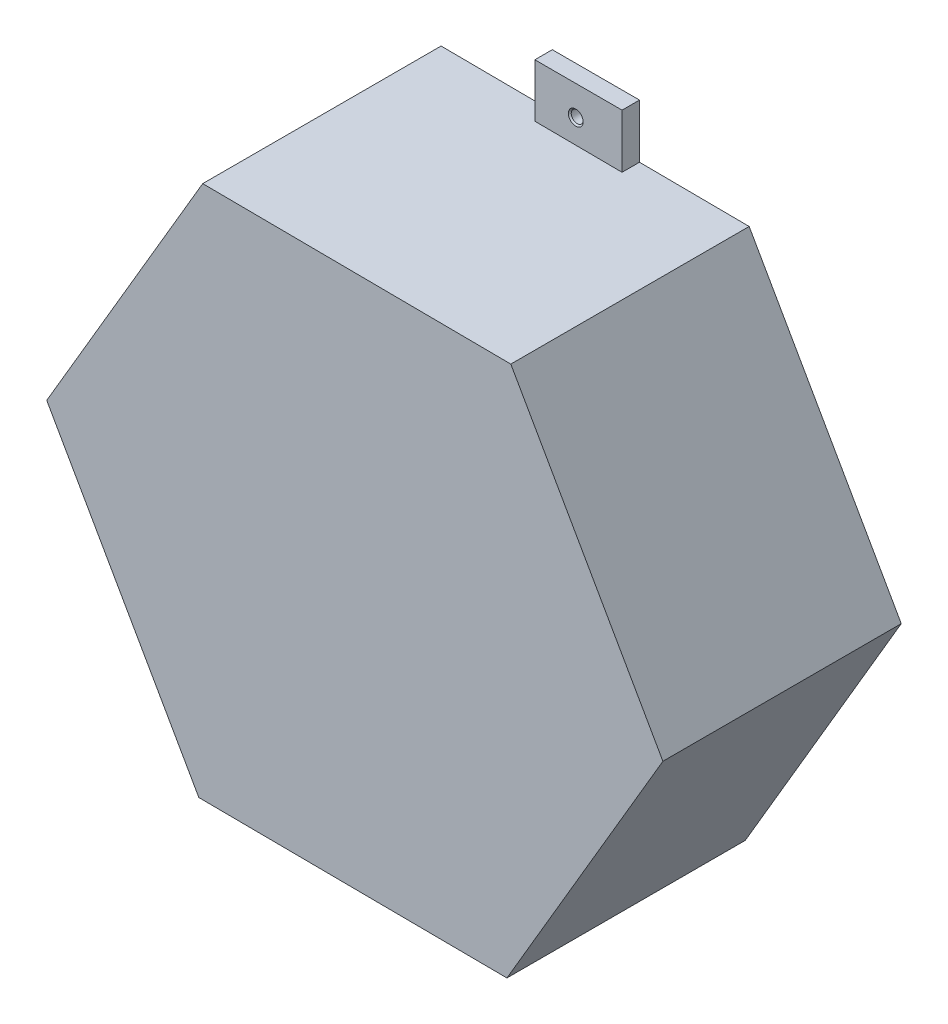
from build123d import *

# Parameters (mm, degrees)
BOSS_EXTRUDE4_DEPTH                = 40
BOSS_EXTRUDE4_DEPTH_BACK           = 1
SKETCH10_R                         = 44
CUT_EXTRUDE3_DEPTH                 = 38
SKETCH11_W                         = 15
SKETCH11_H                         = 10
BOSS_EXTRUDE5_DEPTH                = 3
M2_5X0_45_TAPPED_HOLE3_D           = 2.05
M2_5X0_45_TAPPED_HOLE3_CSINK_D     = 2.55
M2_5X0_45_TAPPED_HOLE3_CSINK_ANGLE = 90
BOSS_EXTRUDE6_DEPTH                = 41
SKETCH17_R                         = 44
CUT_EXTRUDE4_DEPTH                 = 38


with BuildPart() as part:
    # Sketch1 → Boss-Extrude4 (new body, two sides)
    with BuildSketch(Plane.XY) as boss_extrude4_sk:
        Polygon((52.078255867, 0), (26.039127933, 45.101092565), (-26.039127933, 45.101092565), (-52.078255867, 0), (-26.039127933, -45.101092565), (26.039127933, -45.101092565), align=None)
    extrude(amount=BOSS_EXTRUDE4_DEPTH)
    extrude(boss_extrude4_sk.sketch, amount=-BOSS_EXTRUDE4_DEPTH_BACK)

    # Sketch10 → Cut-Extrude3 (cut)
    with BuildSketch(Plane(origin=(0, 0, -1), x_dir=(-1, 0, 0), z_dir=(0, 0, -1))):
        Circle(SKETCH10_R)
    extrude(amount=-CUT_EXTRUDE3_DEPTH, mode=Mode.SUBTRACT)

    # Sketch11 → Boss-Extrude5 (add)
    with BuildSketch(Plane(origin=(0, 0, -1), x_dir=(-1, 0, 0), z_dir=(0, 0, -1))):
        with Locations((-0.468011799, 50.101092565)):
            Rectangle(SKETCH11_W, SKETCH11_H)
        with Locations((-0.468011799, -50.101092565)):
            Rectangle(SKETCH11_W, SKETCH11_H)
    extrude(amount=-BOSS_EXTRUDE5_DEPTH)

    # M2.5x0.45 Tapped Hole3 (through all)
    with Locations(Plane.XY.offset(2)):
        with Locations((0, 50), (0, -50)):
            CounterSinkHole(M2_5X0_45_TAPPED_HOLE3_D / 2, M2_5X0_45_TAPPED_HOLE3_CSINK_D / 2, counter_sink_angle=M2_5X0_45_TAPPED_HOLE3_CSINK_ANGLE)

    # Sketch16 → Boss-Extrude6 (add)
    with BuildSketch(Plane.XY.offset(40)):
        Polygon((-52.993622647, 0.385678178), (-26.830818423, -45.700984362), (26.162804224, -46.08666254), (52.993622647, -0.385678178), (26.830818423, 45.700984362), (-26.162804224, 46.08666254), align=None)
    extrude(amount=-BOSS_EXTRUDE6_DEPTH)

    # Sketch17 → Cut-Extrude4 (cut)
    with BuildSketch(Plane(origin=(0, 0, -1), x_dir=(-1, 0, 0), z_dir=(0, 0, -1))):
        Circle(SKETCH17_R)
    extrude(amount=-CUT_EXTRUDE4_DEPTH, mode=Mode.SUBTRACT)


solid = part.part
